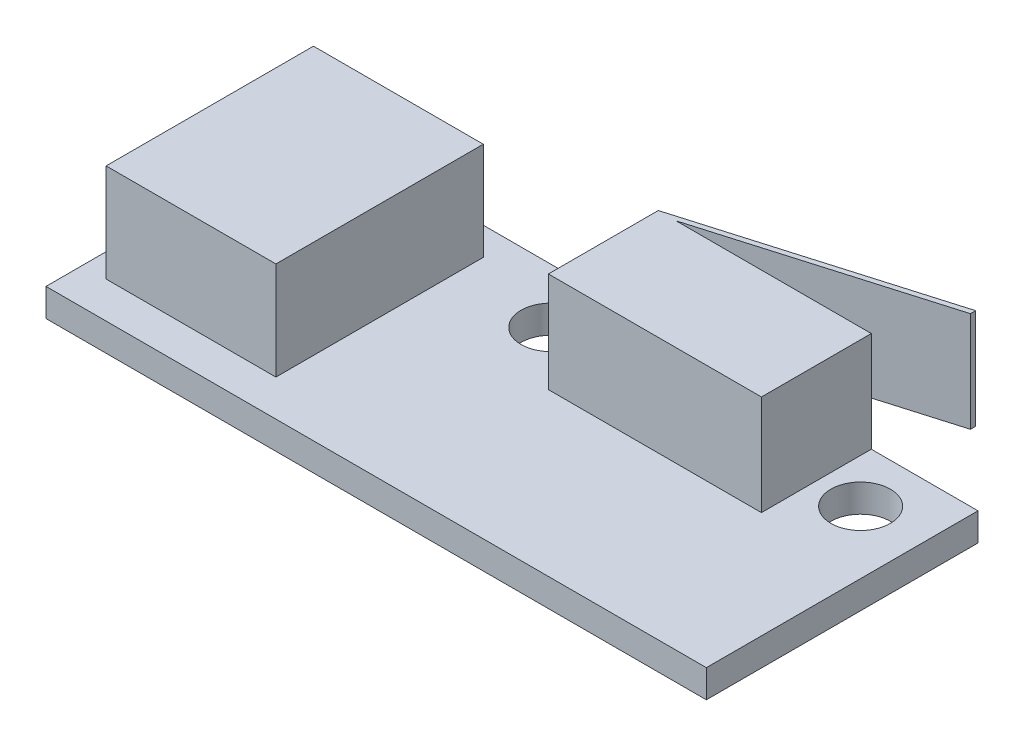
from build123d import *

# Parameters (mm, degrees)
SKETCH1_W           = 39.55
SKETCH1_H           = 16.27
BOSS_EXTRUDE1_DEPTH = 1.67
BOSS_EXTRUDE2_DEPTH = 6
SKETCH3_W           = 10.17
SKETCH3_H           = 12.42
BOSS_EXTRUDE3_DEPTH = 5.87
SKETCH4_R           = 1.78
CUT_EXTRUDE1_DEPTH  = 2.67


with BuildPart() as part:
    # Sketch1 → Boss-Extrude1 (new body)
    with BuildSketch(Plane(origin=(0, 0, 0), x_dir=(1, 0, 0), z_dir=(0, 1, 0))):
        with Locations((-19.775, 8.135)):
            Rectangle(SKETCH1_W, SKETCH1_H)
    extrude(amount=BOSS_EXTRUDE1_DEPTH)

    # Sketch2 → Boss-Extrude2 (add)
    with BuildSketch(Plane(origin=(0, 1.67, 0), x_dir=(1, 0, 0), z_dir=(0, 1, 0))):
        Polygon((-4.45, 20.582644068), (-19.15, 16.27), (-18.084327124, 16.27), (-4.45, 20.27), align=None)
        Polygon((-18.084327124, 16.27), (-19.15, 16.27), (-19.15, 9.69), (-6.39, 9.69), (-6.39, 16.27), align=None)
    extrude(amount=BOSS_EXTRUDE2_DEPTH)

    # Sketch3 → Boss-Extrude3 (add)
    with BuildSketch(Plane(origin=(0, 1.67, 0), x_dir=(1, 0, 0), z_dir=(0, 1, 0))):
        with Locations((-33.045, 8.39)):
            Rectangle(SKETCH3_W, SKETCH3_H)
    extrude(amount=BOSS_EXTRUDE3_DEPTH)

    # Sketch4 → Cut-Extrude1 (cut, through all)
    with BuildSketch(Plane(origin=(0, 1.67, 0), x_dir=(1, 0, 0), z_dir=(0, 1, 0))):
        with Locations((-22.31, 12.99)):
            Circle(SKETCH4_R)
        with Locations((-3.75, 12.99)):
            Circle(SKETCH4_R)
    extrude(amount=-CUT_EXTRUDE1_DEPTH, mode=Mode.SUBTRACT)


solid = part.part
